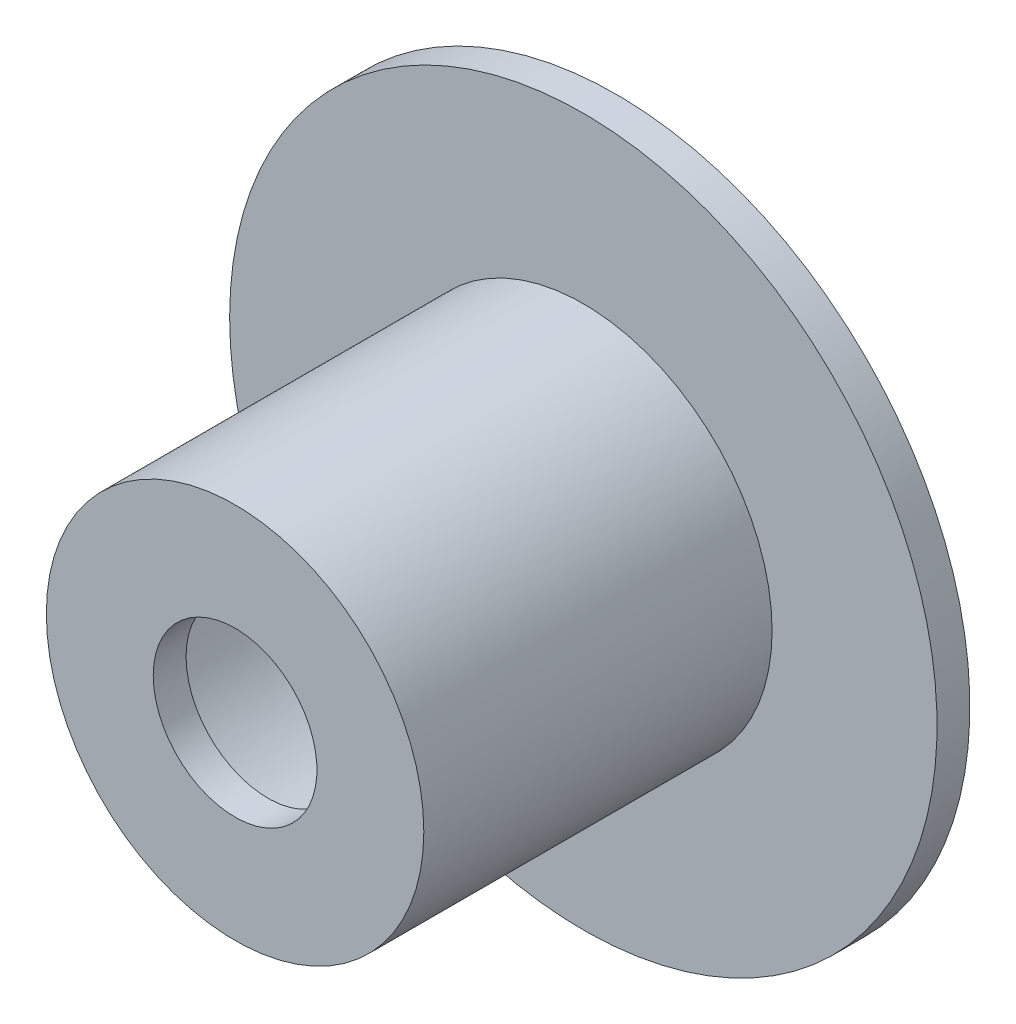
from build123d import *


with BuildPart() as part:
    # Sketch2 → Revolve1 (revolve)
    with BuildSketch(Plane.ZY.offset(-259.301545348)):
        Polygon((4, -105.47061945), (4, -125.573704322), (46.438180449, -125.573704322), (46.438180449, -138.59916661), (42.438180449, -138.59916661), (42.438180449, -128.573704322), (0, -128.573704322), (0, -105.47061945), align=None)
    revolve(axis=Axis((259.301545348, -148.573704322, -5), (0, 0, 1)))


solid = part.part
